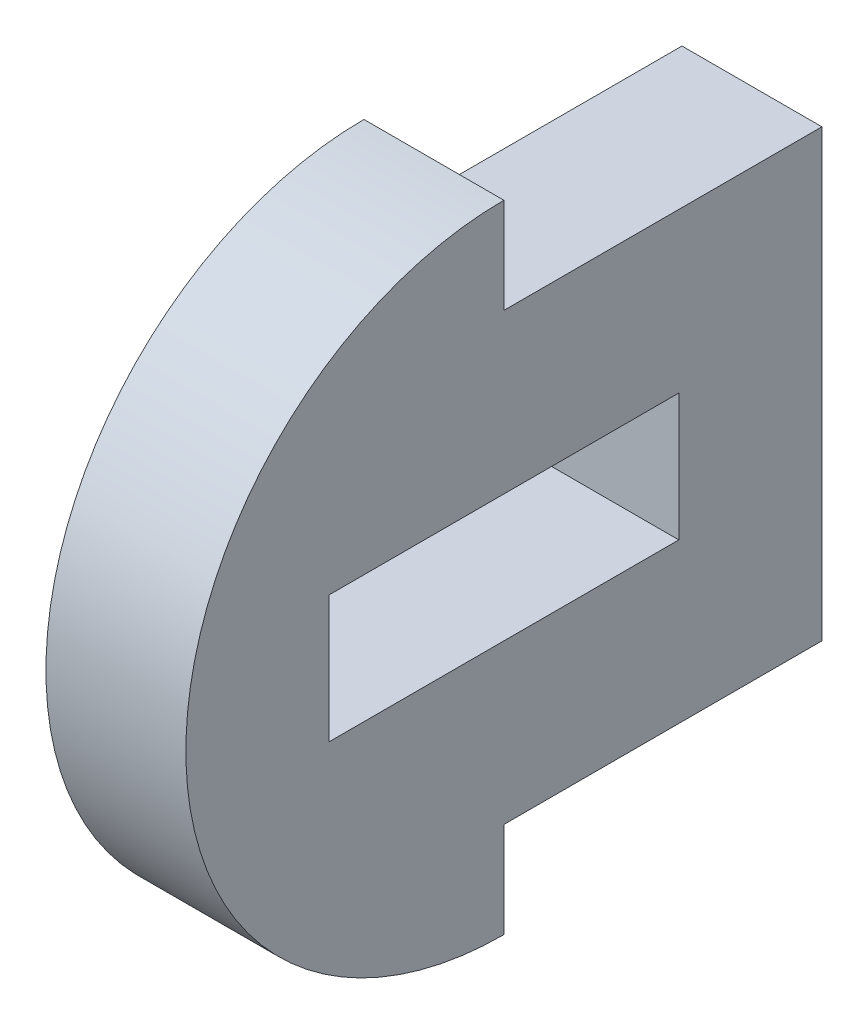
from build123d import *

# Parameters (mm, degrees)
SKETCH1_W           = 11
SKETCH1_H           = 4
BOSS_EXTRUDE1_DEPTH = 4.4


with BuildPart() as part:
    # Sketch1 → Boss-Extrude1 (new body)
    with BuildSketch(Plane(origin=(0, 0, 0), x_dir=(0, 0, -1), z_dir=(1, 0, 0))):
        with BuildLine():
            Line((0, 10), (0, 7))
            Line((0, 7), (10, 7))
            Line((10, 7), (10, -7))
            Line((10, -7), (0, -7))
            Line((0, -7), (0, -10))
            ThreePointArc((0, -10), (-10, 0), (0, 10))
        make_face()
        Rectangle(SKETCH1_W, SKETCH1_H, mode=Mode.SUBTRACT)
    extrude(amount=BOSS_EXTRUDE1_DEPTH)


solid = part.part
